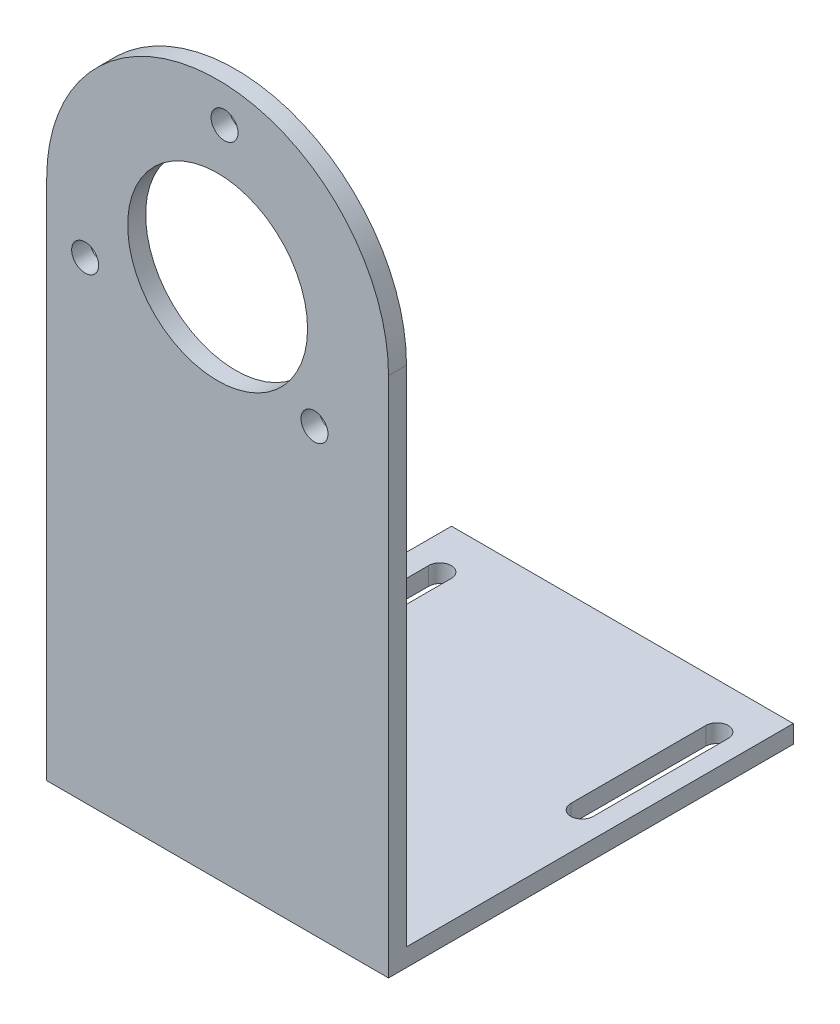
from build123d import *

# Parameters (mm, degrees)
SKETCH1_W           = 38
SKETCH1_H           = 45
BOSS_EXTRUDE1_DEPTH = 2
SKETCH3_R           = 19
SKETCH3_R_2         = 10
BOSS_EXTRUDE2_DEPTH = 2
BOSS_EXTRUDE3_DEPTH = 2
CUT_EXTRUDE1_DEPTH  = 2
SKETCH6_R           = 1.5
CUT_EXTRUDE2_DEPTH  = 2


with BuildPart() as part:
    # Sketch1 → Boss-Extrude1 (new body)
    with BuildSketch(Plane(origin=(0, 0, 0), x_dir=(1, 0, 0), z_dir=(0, 1, 0))):
        with Locations((-12.77026585, -1.948212393)):
            Rectangle(SKETCH1_W, SKETCH1_H)
    extrude(amount=BOSS_EXTRUDE1_DEPTH)



with BuildPart() as body_2:
    # Sketch3 → Boss-Extrude2 (new body)
    with BuildSketch(Plane.XY.offset(24.448212393)):
        with Locations((-12.77026585, 58)):
            Circle(SKETCH3_R)
        with Locations((-12.77026585, 58)):
            Circle(SKETCH3_R_2, mode=Mode.SUBTRACT)
    extrude(amount=-BOSS_EXTRUDE2_DEPTH)


with BuildPart() as part_1:
    add(part.part)

    add(body_2.part)  # Boss-Extrude3 merges body 2
    # Sketch3_4 → Boss-Extrude3 (add)
    with BuildSketch(Plane.XY.offset(24.448212393)):
        with BuildLine():
            Line((-31.77026585, 2), (6.22973415, 2))
            Line((6.22973415, 2), (6.22973415, 58))
            ThreePointArc((6.22973415, 58), (-12.77026585, 39), (-31.77026585, 58))
            Line((-31.77026585, 58), (-31.77026585, 2))
        make_face()
    extrude(amount=-BOSS_EXTRUDE3_DEPTH)

    # Sketch4 → Cut-Extrude1 (cut)
    with BuildSketch(Plane(origin=(0, 2, 0), x_dir=(1, 0, 0), z_dir=(0, 1, 0))):
        with BuildLine():
            Line((1.55, 0.5), (1.55, 15.5))
            ThreePointArc((1.55, 15.5), (2.8, 16.75), (4.05, 15.5))
            Line((4.05, 15.5), (4.05, 0.5))
            ThreePointArc((4.05, 0.5), (2.8, -0.75), (1.55, 0.5))
        make_face()
        with BuildLine():
            Line((-29.25, 0.5), (-29.25, 15.5))
            ThreePointArc((-29.25, 15.5), (-28, 16.75), (-26.75, 15.5))
            Line((-26.75, 15.5), (-26.75, 0.5))
            ThreePointArc((-26.75, 0.5), (-28, -0.75), (-29.25, 0.5))
        make_face()
    extrude(amount=-CUT_EXTRUDE1_DEPTH, mode=Mode.SUBTRACT)

    # Sketch6 → Cut-Extrude2 (cut)
    with BuildSketch(Plane.XY.offset(24.448212393)):
        with Locations((-12, 73)):
            Circle(SKETCH6_R)
        with Locations((-2, 49)):
            Circle(SKETCH6_R)
        with Locations((-27.5, 52.5)):
            Circle(SKETCH6_R)
    extrude(amount=-CUT_EXTRUDE2_DEPTH, mode=Mode.SUBTRACT)


solid = part_1.part
